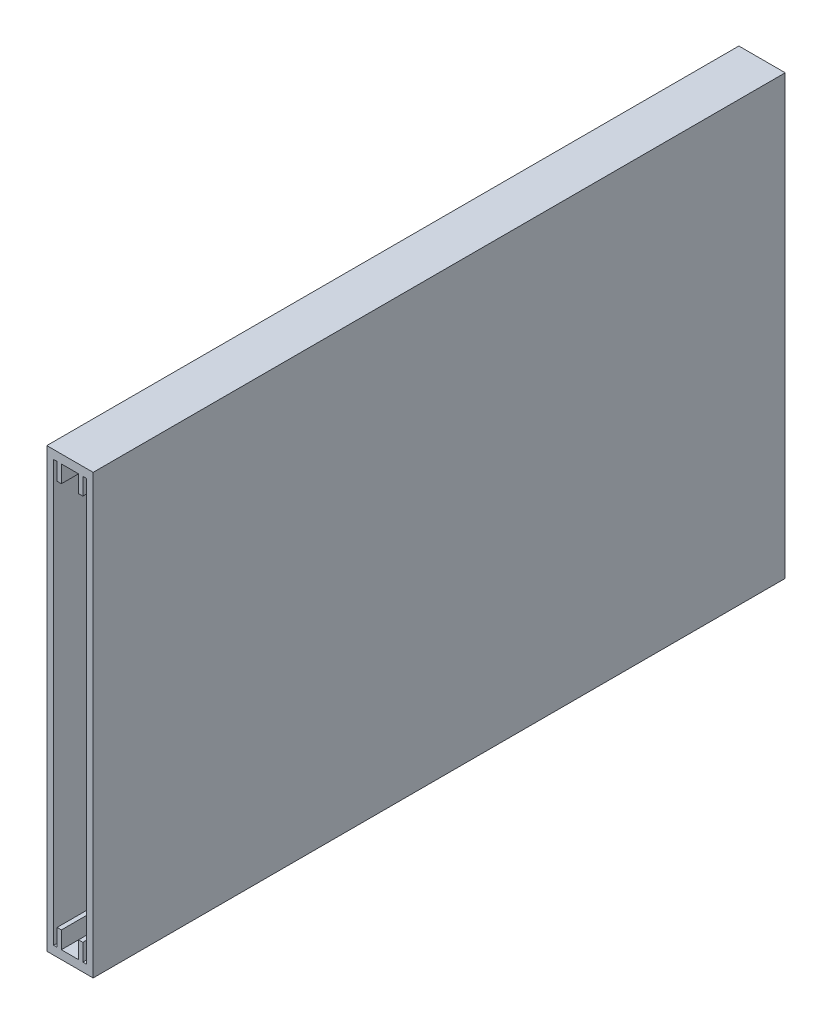
from build123d import *

# Parameters (mm, degrees)
SKETCH1_W           = 102
SKETCH1_H           = 10.8
BOSS_EXTRUDE1_DEPTH = 1.2
SKETCH2_W           = 10.8
SKETCH2_H           = 102
BOSS_EXTRUDE2_DEPTH = 160


with BuildPart() as part:
    # Sketch1 → Boss-Extrude1 (new body)
    with BuildSketch(Plane(origin=(0, 0, 0), x_dir=(0, 1, 0), z_dir=(0, 0, 1))):
        with Locations((51, 5.4)):
            Rectangle(SKETCH1_W, SKETCH1_H)
    extrude(amount=BOSS_EXTRUDE1_DEPTH)

    # Sketch2 → Boss-Extrude2 (add)
    with BuildSketch(Plane.XY.offset(1.2)):
        with Locations((-5.4, 51)):
            Rectangle(SKETCH2_W, SKETCH2_H)
        Polygon((-9.2, 100), (-8.4, 100), (-8.4, 96), (-7.4, 96), (-7.4, 100), (-3.4, 100), (-3.4, 96), (-2.4, 96), (-2.4, 100), (-1.6, 100), (-1.6, 2), (-2.4, 2), (-2.4, 6), (-3.4, 6), (-3.4, 2), (-7.4, 2), (-7.4, 6), (-8.4, 6), (-8.4, 2), (-9.2, 2), align=None, mode=Mode.SUBTRACT)
    extrude(amount=BOSS_EXTRUDE2_DEPTH)


solid = part.part
